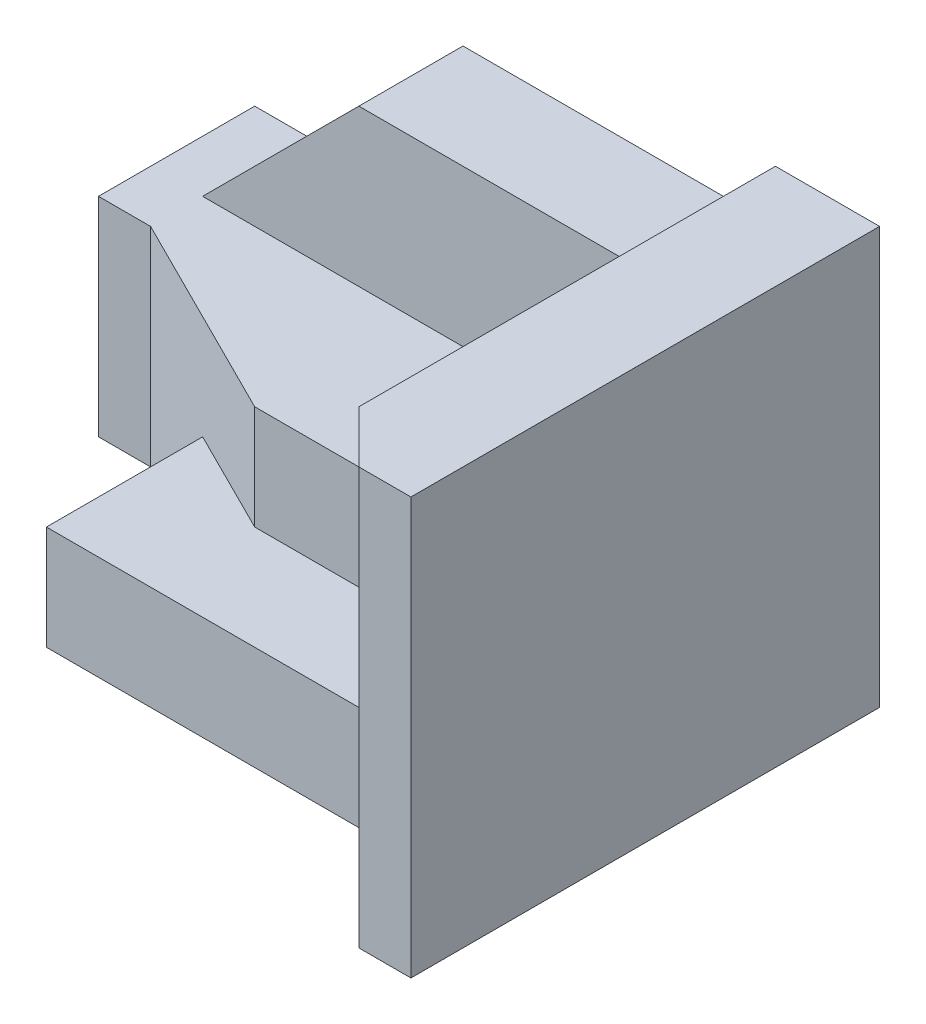
from build123d import *

# Parameters (mm, degrees)
SKETCH1_W           = 120
SKETCH1_H           = 80
BOSS_EXTRUDE1_DEPTH = 90
CUT_EXTRUDE1_DEPTH  = 90
CUT_EXTRUDE2_DEPTH  = 90
CUT_EXTRUDE3_DEPTH  = 90
CUT_EXTRUDE4_DEPTH  = 90
CUT_EXTRUDE5_DEPTH  = 90


with BuildPart() as part:
    # Sketch1 → Boss-Extrude1 (new body)
    with BuildSketch(Plane.XY):
        with Locations((60, 40)):
            Rectangle(SKETCH1_W, SKETCH1_H)
    extrude(amount=-BOSS_EXTRUDE1_DEPTH)

    # Sketch2 → Cut-Extrude1 (cut)
    with BuildSketch(Plane.XY):
        Polygon((0, 40), (10, 40), (40, 70), (100, 70), (100, 80), (0, 80), align=None)
    extrude(amount=-CUT_EXTRUDE1_DEPTH, mode=Mode.SUBTRACT)

    # Sketch3 → Cut-Extrude2 (cut)
    with BuildSketch(Plane.XZ):
        Polygon((0, -60), (10, -60), (30, -50), (30, -20), (90, -20), (110, 0), (0, 0), align=None)
    extrude(amount=-CUT_EXTRUDE2_DEPTH, mode=Mode.SUBTRACT)

    # Sketch4 → Cut-Extrude3 (cut)
    with BuildSketch(Plane(origin=(0, 20, 0), x_dir=(1, 0, 0), z_dir=(0, 1, 0))):
        Polygon((30, 20), (30, 50), (50, 40), (70, 40), (90, 20), align=None)
    extrude(amount=CUT_EXTRUDE3_DEPTH, mode=Mode.SUBTRACT)

    # Sketch5 → Cut-Extrude4 (cut)
    with BuildSketch(Plane(origin=(0, 40, 0), x_dir=(1, 0, 0), z_dir=(0, 1, 0))):
        Polygon((70, 40), (70, 70), (10, 70), (10, 60), (50, 40), align=None)
    extrude(amount=CUT_EXTRUDE4_DEPTH, mode=Mode.SUBTRACT)

    # Sketch6 → Cut-Extrude5 (cut)
    with BuildSketch(Plane.XY.offset(-70)):
        Polygon((70, 40), (100, 70), (70, 70), align=None)
    extrude(amount=CUT_EXTRUDE5_DEPTH, mode=Mode.SUBTRACT)


solid = part.part
